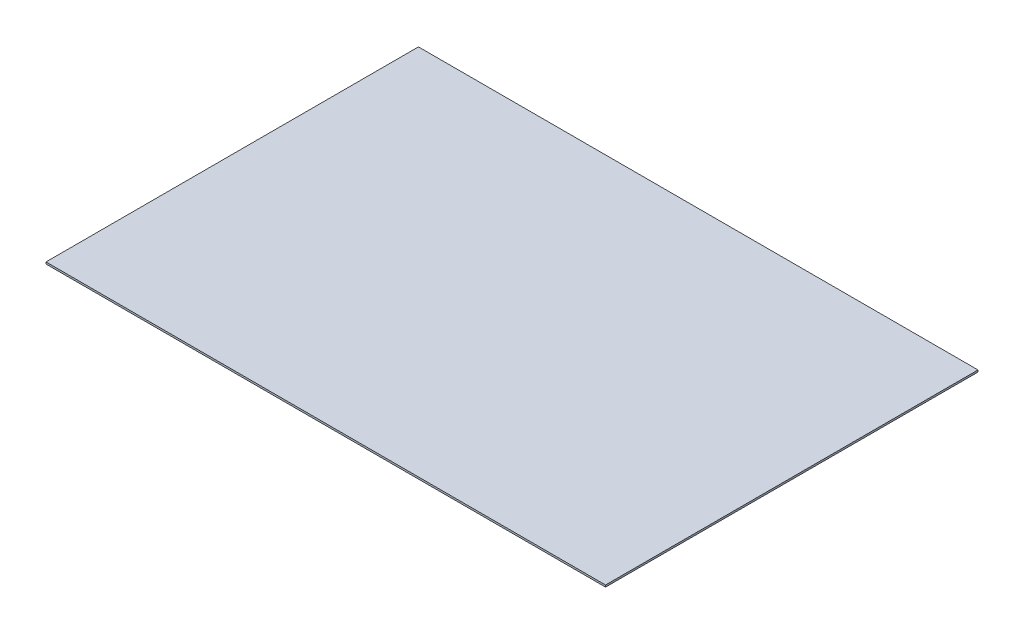
from build123d import *

# Parameters (mm, degrees)
SKETCH1_W           = 600
SKETCH1_H           = 399.38
BOSS_EXTRUDE1_DEPTH = 2


with BuildPart() as part:
    # Sketch1 → Boss-Extrude1 (new body)
    with BuildSketch(Plane(origin=(0, 0, 0), x_dir=(1, 0, 0), z_dir=(0, 1, 0))):
        with Locations((300, 199.69)):
            Rectangle(SKETCH1_W, SKETCH1_H)
    extrude(amount=BOSS_EXTRUDE1_DEPTH)


solid = part.part
